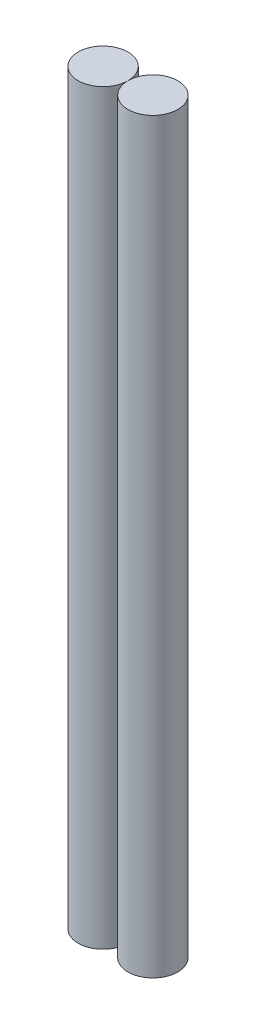
from build123d import *

# Parameters (mm, degrees)
SKETCH1_R             = 9
BOSS_EXTRUDE1_DEPTH   = 270
BOSS_EXTRUDE1_2_DEPTH = 270


with BuildPart() as part:
    # Sketch1 → Boss-Extrude1 (new body)
    with BuildSketch(Plane(origin=(0, 0, 0), x_dir=(1, 0, 0), z_dir=(0, 1, 0))):
        Circle(SKETCH1_R)
    extrude(amount=BOSS_EXTRUDE1_DEPTH)


with BuildPart() as body_2:
    # Sketch1 → Boss-Extrude1 2 (new body)
    with BuildSketch(Plane(origin=(0, 0, 0), x_dir=(1, 0, 0), z_dir=(0, 1, 0))):
        with Locations((18, 0)):
            Circle(SKETCH1_R)
    extrude(amount=BOSS_EXTRUDE1_2_DEPTH)


solid = Compound([part.part, body_2.part])
